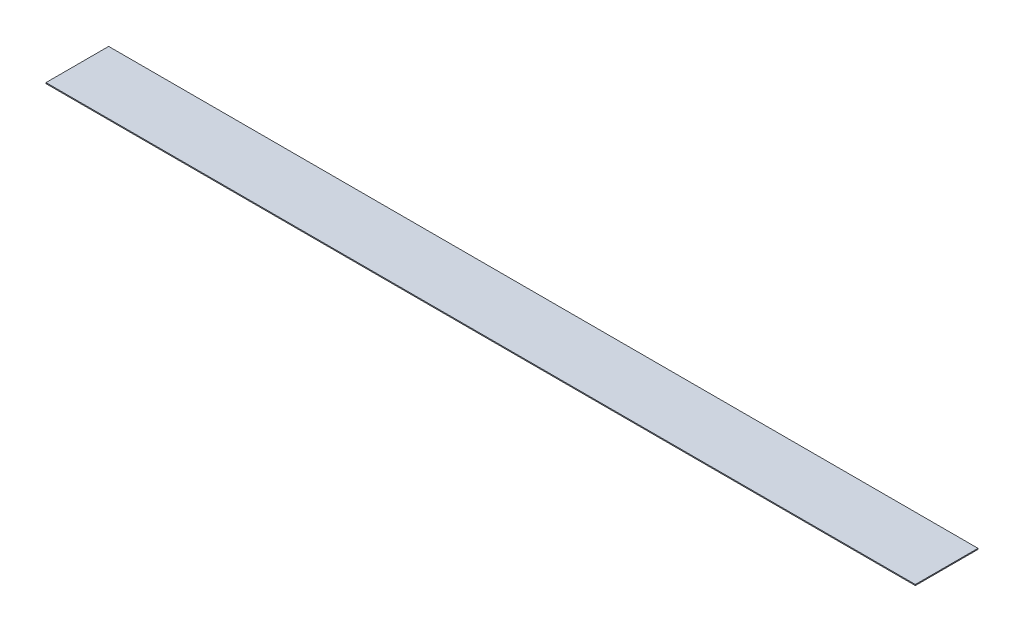
from build123d import *

# Parameters (mm, degrees)
SKETCH2_W           = 1409.7
SKETCH2_H           = 101.6
BOSS_EXTRUDE1_DEPTH = 1.5875


with BuildPart() as part:
    # Sketch2 → Boss-Extrude1 (new body)
    with BuildSketch(Plane(origin=(0, 0, 0), x_dir=(1, 0, 0), z_dir=(0, 1, 0))):
        with Locations((704.85, -50.8)):
            Rectangle(SKETCH2_W, SKETCH2_H)
    extrude(amount=BOSS_EXTRUDE1_DEPTH)


solid = part.part
